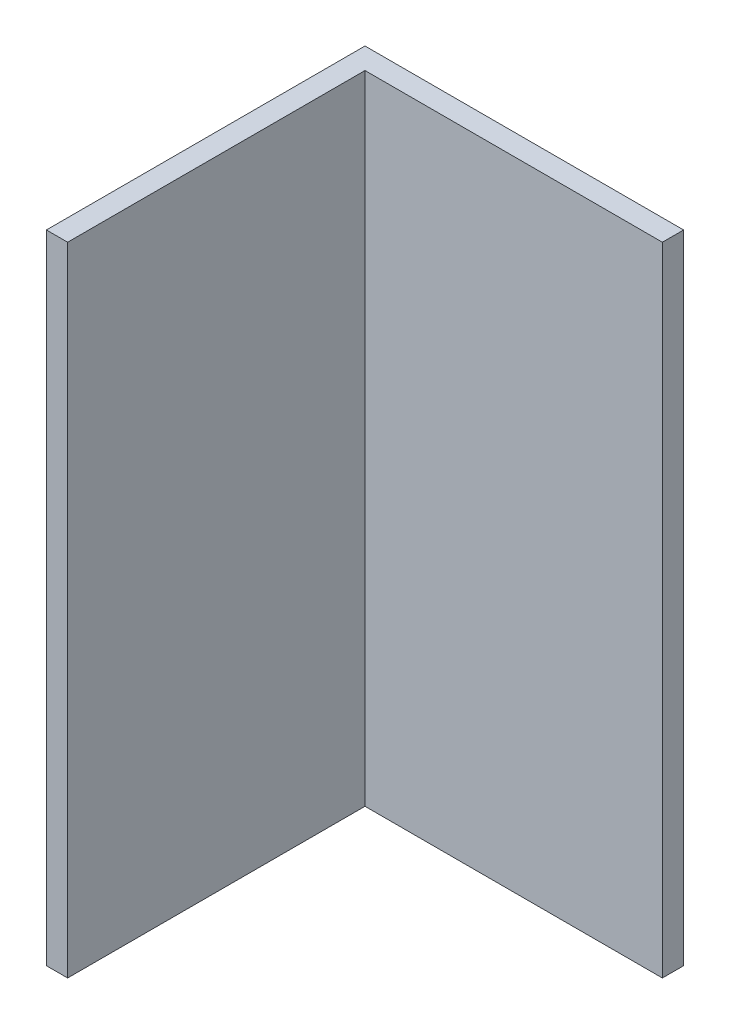
from build123d import *

# Parameters (mm, degrees)
BOSS_EXTRUDE1_DEPTH = 60


with BuildPart() as part:
    # Sketch1 → Boss-Extrude1 (new body)
    with BuildSketch(Plane(origin=(0, 0, 0), x_dir=(1, 0, 0), z_dir=(0, 1, 0))):
        Polygon((0, 0), (0, -30), (2, -30), (2, -2), (30, -2), (30, 0), align=None)
    extrude(amount=BOSS_EXTRUDE1_DEPTH)


solid = part.part
